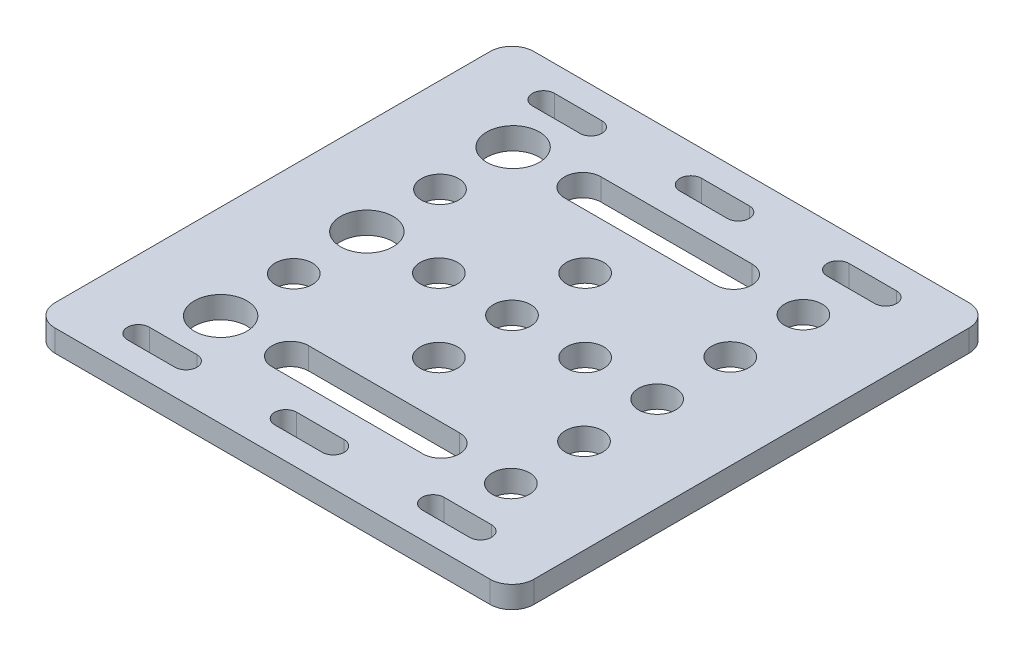
from build123d import *

# Parameters (mm, degrees)
SKETCH1_R           = 2.55
SKETCH1_R_2         = 3.6
BOSS_EXTRUDE1_DEPTH = 3


with BuildPart() as part:
    # Sketch1 → Boss-Extrude1 (new body)
    with BuildSketch(Plane(origin=(0, 0, 0), x_dir=(1, 0, 0), z_dir=(0, 1, 0))):
        with BuildLine():
            Line((29.75, -32.75), (-29.75, -32.75))
            ThreePointArc((-29.75, -32.75), (-31.871320344, -31.871320344), (-32.75, -29.75))
            Line((-32.75, -29.75), (-32.75, 29.75))
            ThreePointArc((-32.75, 29.75), (-31.871320344, 31.871320344), (-29.75, 32.75))
            Line((-29.75, 32.75), (29.75, 32.75))
            ThreePointArc((29.75, 32.75), (31.871320344, 31.871320344), (32.75, 29.75))
            Line((32.75, 29.75), (32.75, -29.75))
            ThreePointArc((32.75, -29.75), (31.871320344, -31.871320344), (29.75, -32.75))
        make_face()
        with Locations((0, 10)):
            Circle(SKETCH1_R, mode=Mode.SUBTRACT)
        Circle(SKETCH1_R, mode=Mode.SUBTRACT)
        with Locations((10, 0)):
            Circle(SKETCH1_R, mode=Mode.SUBTRACT)
        with Locations((-10, 0)):
            Circle(SKETCH1_R, mode=Mode.SUBTRACT)
        with Locations((-19.85, 20)):
            Circle(SKETCH1_R_2, mode=Mode.SUBTRACT)
        with Locations((-19.85, 0)):
            Circle(SKETCH1_R_2, mode=Mode.SUBTRACT)
        with Locations((-19.85, -20)):
            Circle(SKETCH1_R_2, mode=Mode.SUBTRACT)
        with Locations((-19.85, 10)):
            Circle(SKETCH1_R, mode=Mode.SUBTRACT)
        with Locations((19.85, 20)):
            Circle(SKETCH1_R, mode=Mode.SUBTRACT)
        with Locations((19.85, 0)):
            Circle(SKETCH1_R, mode=Mode.SUBTRACT)
        with Locations((19.85, -20)):
            Circle(SKETCH1_R, mode=Mode.SUBTRACT)
        with Locations((0, -10)):
            Circle(SKETCH1_R, mode=Mode.SUBTRACT)
        with Locations((19.85, 10)):
            Circle(SKETCH1_R, mode=Mode.SUBTRACT)
        with Locations((19.85, -10)):
            Circle(SKETCH1_R, mode=Mode.SUBTRACT)
        with Locations((-19.85, -10)):
            Circle(SKETCH1_R, mode=Mode.SUBTRACT)
        with BuildLine():
            Line((10.32, 17.5), (-10.32, 17.5))
            ThreePointArc((-10.32, 17.5), (-12.82, 20), (-10.32, 22.5))
            Line((-10.32, 22.5), (10.32, 22.5))
            ThreePointArc((10.32, 22.5), (12.82, 20), (10.32, 17.5))
        make_face(mode=Mode.SUBTRACT)
        with BuildLine():
            Line((3.25, 26.2), (-3.25, 26.2))
            ThreePointArc((-3.25, 26.2), (-4.75, 27.7), (-3.25, 29.2))
            Line((-3.25, 29.2), (3.25, 29.2))
            ThreePointArc((3.25, 29.2), (4.75, 27.7), (3.25, 26.2))
        make_face(mode=Mode.SUBTRACT)
        with BuildLine():
            Line((-16.9, 26.2), (-23.4, 26.2))
            ThreePointArc((-23.4, 26.2), (-24.9, 27.7), (-23.4, 29.2))
            Line((-23.4, 29.2), (-16.9, 29.2))
            ThreePointArc((-16.9, 29.2), (-15.4, 27.7), (-16.9, 26.2))
        make_face(mode=Mode.SUBTRACT)
        with BuildLine():
            Line((16.9, 26.2), (23.4, 26.2))
            ThreePointArc((23.4, 26.2), (24.9, 27.7), (23.4, 29.2))
            Line((23.4, 29.2), (16.9, 29.2))
            ThreePointArc((16.9, 29.2), (15.4, 27.7), (16.9, 26.2))
        make_face(mode=Mode.SUBTRACT)
        with BuildLine():
            Line((10.32, -17.5), (-10.32, -17.5))
            ThreePointArc((-10.32, -17.5), (-12.82, -20), (-10.32, -22.5))
            Line((-10.32, -22.5), (10.32, -22.5))
            ThreePointArc((10.32, -22.5), (12.82, -20), (10.32, -17.5))
        make_face(mode=Mode.SUBTRACT)
        with BuildLine():
            Line((-16.9, -26.2), (-23.4, -26.2))
            ThreePointArc((-23.4, -26.2), (-24.9, -27.7), (-23.4, -29.2))
            Line((-23.4, -29.2), (-16.9, -29.2))
            ThreePointArc((-16.9, -29.2), (-15.4, -27.7), (-16.9, -26.2))
        make_face(mode=Mode.SUBTRACT)
        with BuildLine():
            Line((3.25, -26.2), (-3.25, -26.2))
            ThreePointArc((-3.25, -26.2), (-4.75, -27.7), (-3.25, -29.2))
            Line((-3.25, -29.2), (3.25, -29.2))
            ThreePointArc((3.25, -29.2), (4.75, -27.7), (3.25, -26.2))
        make_face(mode=Mode.SUBTRACT)
        with BuildLine():
            Line((16.9, -26.2), (23.4, -26.2))
            ThreePointArc((23.4, -26.2), (24.9, -27.7), (23.4, -29.2))
            Line((23.4, -29.2), (16.9, -29.2))
            ThreePointArc((16.9, -29.2), (15.4, -27.7), (16.9, -26.2))
        make_face(mode=Mode.SUBTRACT)
    extrude(amount=BOSS_EXTRUDE1_DEPTH)


solid = part.part
